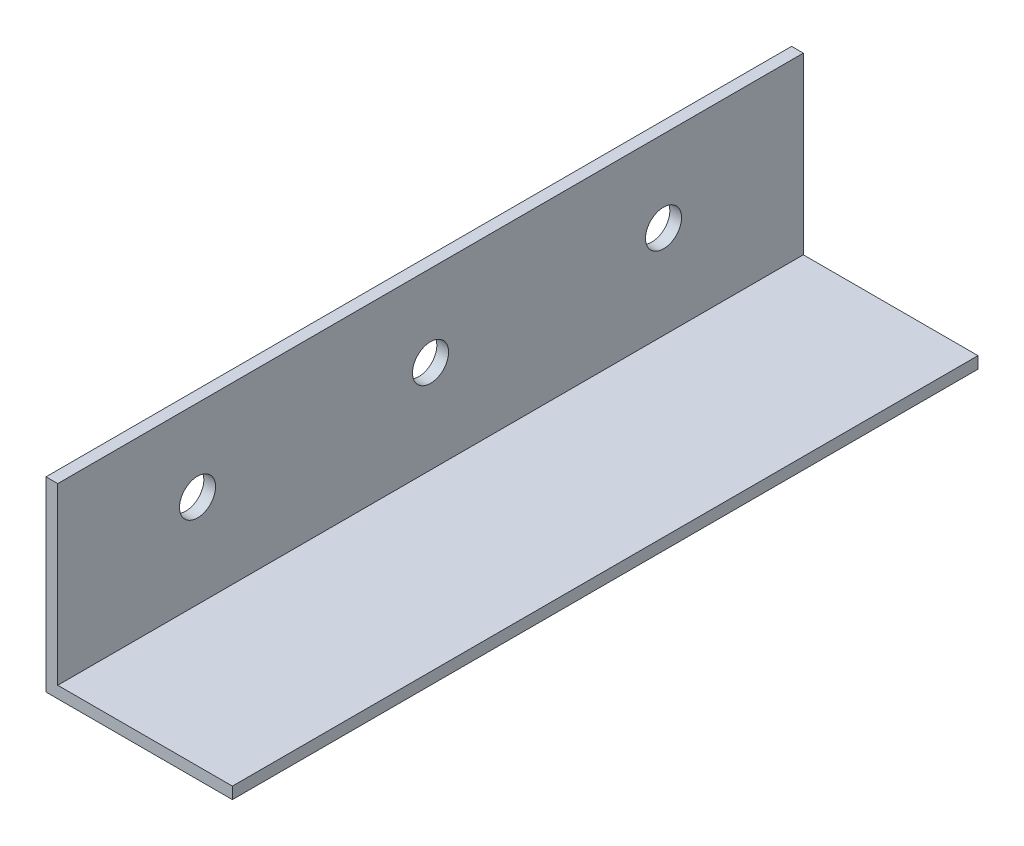
from build123d import *

# Parameters (mm, degrees)
BOSS_EXTRUDE1_DEPTH          = 101.6
F_10_0_1935_DIAMETER_HOLE1_D = 4.9149


with BuildPart() as part:
    # Sketch1 → Boss-Extrude1 (new body)
    with BuildSketch(Plane.XY):
        Polygon((0, 0), (0, 25.4), (1.6002, 25.4), (1.6002, 1.6002), (25.4, 1.6002), (25.4, 0), align=None)
    extrude(amount=BOSS_EXTRUDE1_DEPTH)

    # #10 (0.1935) Diameter Hole1 (through all)
    with Locations(Plane(origin=(1.6002, 0, 0), x_dir=(0, 0, -1), z_dir=(1, 0, 0))):
        with Locations((-82.55, 14.2875), (-50.8, 14.2875), (-19.05, 14.2875)):
            Hole(F_10_0_1935_DIAMETER_HOLE1_D / 2)


solid = part.part
